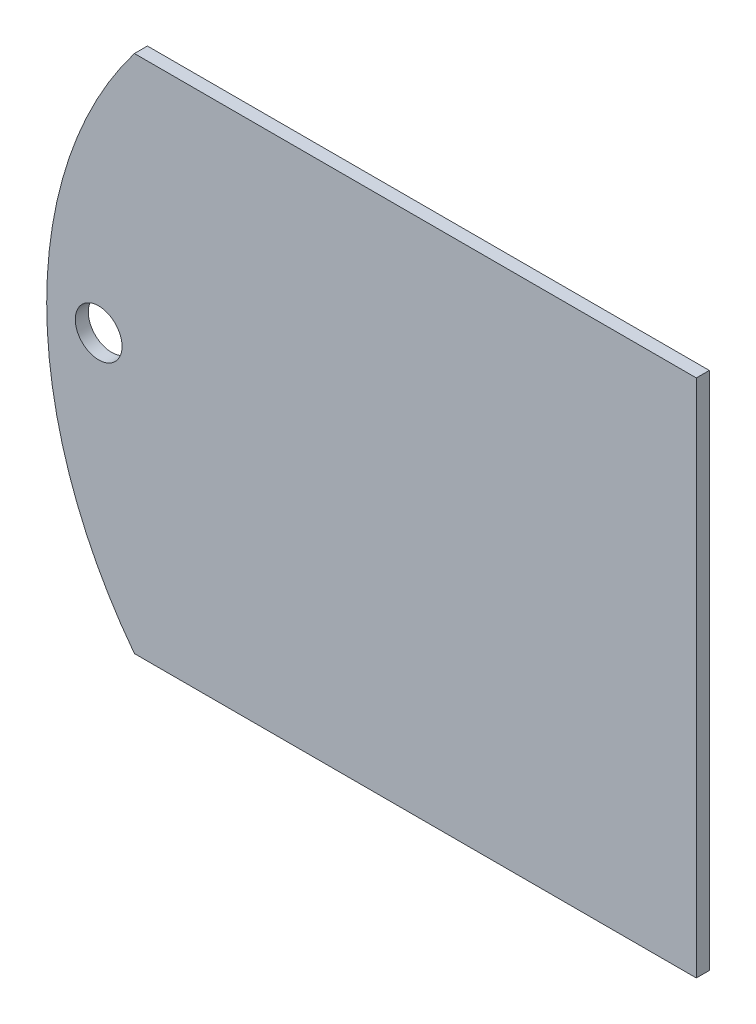
from build123d import *

# Parameters (mm, degrees)
CROQUIS1_R              = 1.8
SALIENTE_EXTRUIR1_DEPTH = 1


with BuildPart() as part:
    # Croquis1 → Saliente-Extruir1 (new body)
    with BuildSketch(Plane.XY):
        with BuildLine():
            ThreePointArc((-26.248809497, 20), (-33, 0), (-26.248809497, -20))
            Line((-26.248809497, -20), (17, -20))
            Line((17, -20), (17, 20))
            Line((17, 20), (-26.248809497, 20))
        make_face()
        with Locations((-29, 0)):
            Circle(CROQUIS1_R, mode=Mode.SUBTRACT)
    extrude(amount=SALIENTE_EXTRUIR1_DEPTH)


solid = part.part
